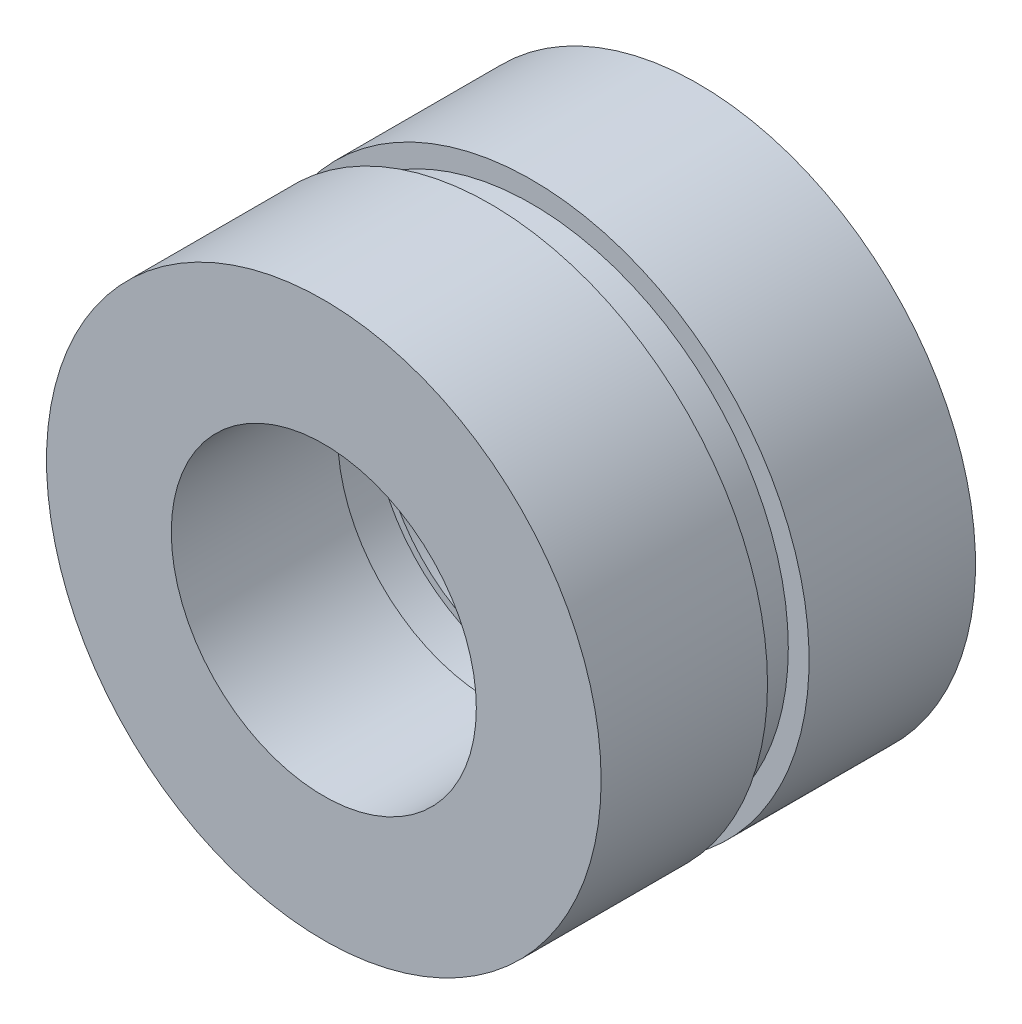
from build123d import *

# Parameters (mm, degrees)
SKETCH1_R           = 4.699
SKETCH1_R_2         = 2.921
BOSS_EXTRUDE2_DEPTH = 0.762
SKETCH3_R           = 5.08
SKETCH3_R_2         = 2.794
BOSS_EXTRUDE3_DEPTH = 3.048
SKETCH4_R           = 5.08
SKETCH4_R_2         = 2.794
BOSS_EXTRUDE4_DEPTH = 3.048


with BuildPart() as part:
    # Sketch1 → Boss-Extrude2 (new body)
    with BuildSketch(Plane.XY):
        Circle(SKETCH1_R)
        Circle(SKETCH1_R_2, mode=Mode.SUBTRACT)
    extrude(amount=BOSS_EXTRUDE2_DEPTH)

    # Sketch3 → Boss-Extrude3 (add)
    with BuildSketch(Plane.XY.offset(0.762)):
        Circle(SKETCH3_R)
        Circle(SKETCH3_R_2, mode=Mode.SUBTRACT)
    extrude(amount=BOSS_EXTRUDE3_DEPTH)


with BuildPart() as body_2:
    # Sketch4 → Boss-Extrude4 (new body)
    with BuildSketch(Plane(origin=(0, 0, 0), x_dir=(-1, 0, 0), z_dir=(0, 0, -1))):
        Circle(SKETCH4_R)
        Circle(SKETCH4_R_2, mode=Mode.SUBTRACT)
    extrude(amount=BOSS_EXTRUDE4_DEPTH)


solid = Compound([part.part, body_2.part])
